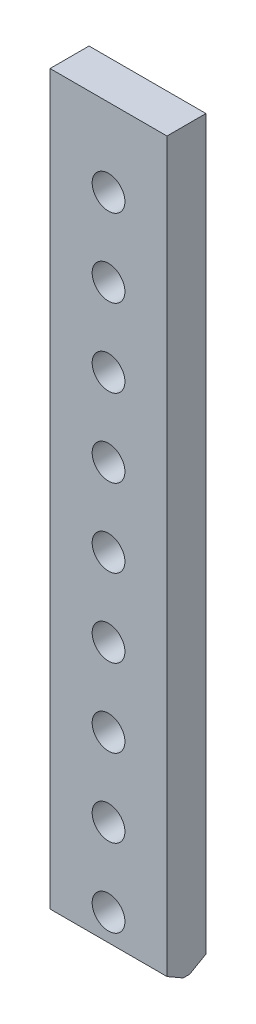
from build123d import *

# Parameters (mm, degrees)
SKETCH_1_W          = 75
SKETCH_1_H          = 473
EXTRUDE_1_DEPTH     = 25
SKETCH_2_R          = 10.5
CUT_EXTRUDE_1_DEPTH = 26
CHAMFER_1_SIZE      = 6
CHAMFER_1_SIZE2     = 10.392304845
CHAMFER_2_SIZE      = 6
CHAMFER_2_SIZE2     = 10.392304845


with BuildPart() as part:
    # Эскиз1 → Бобышка-Вытянуть1 (new body)
    with BuildSketch(Plane.XY):
        with Locations((37.5, 236.5)):
            Rectangle(SKETCH_1_W, SKETCH_1_H)
    extrude(amount=EXTRUDE_1_DEPTH)

    # Эскиз2 → Вырез-Вытянуть1 (cut, through all)
    with BuildSketch(Plane.XY.offset(25)):
        with Locations((37.5, 23)):
            Circle(SKETCH_2_R)
        with Locations((37.5, 73)):
            Circle(SKETCH_2_R)
        with Locations((37.5, 123)):
            Circle(SKETCH_2_R)
        with Locations((37.5, 173)):
            Circle(SKETCH_2_R)
        with Locations((37.5, 223)):
            Circle(SKETCH_2_R)
        with Locations((37.5, 273)):
            Circle(SKETCH_2_R)
        with Locations((37.5, 323)):
            Circle(SKETCH_2_R)
        with Locations((37.5, 373)):
            Circle(SKETCH_2_R)
        with Locations((37.5, 423)):
            Circle(SKETCH_2_R)
    extrude(amount=-CUT_EXTRUDE_1_DEPTH, mode=Mode.SUBTRACT)

    # Фаска1
    chamfer_1_edges = [part.edges().sort_by_distance(p)[0] for p in [
        (37.5, 0, 0),
    ]]
    chamfer_1_side = [part.faces().sort_by_distance(p)[0] for p in [
        (37.5, 237.800547955, 0),
    ]]
    chamfer(chamfer_1_edges, length=CHAMFER_1_SIZE, length2=CHAMFER_1_SIZE2, reference=chamfer_1_side[0])

    # Фаска2
    chamfer_2_edges = [part.edges().sort_by_distance(p)[0] for p in [
        (37.5, 0, 25),
    ]]
    chamfer_2_side = [part.faces().sort_by_distance(p)[0] for p in [
        (37.5, 237.800547955, 25),
    ]]
    chamfer(chamfer_2_edges, length=CHAMFER_2_SIZE, length2=CHAMFER_2_SIZE2, reference=chamfer_2_side[0])


solid = part.part
